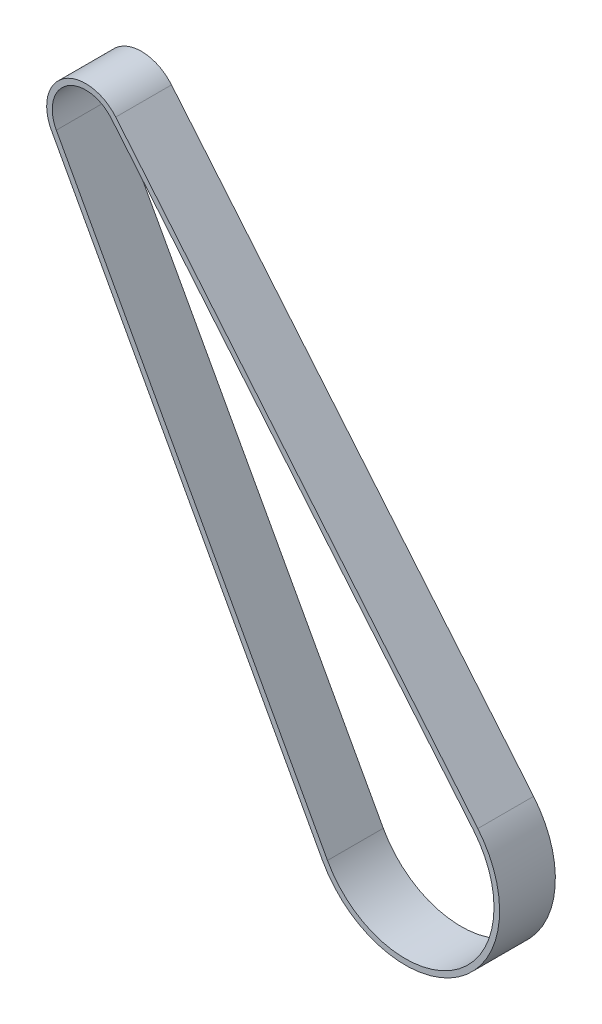
from build123d import *

# Parameters (mm, degrees)
EXTRU_MINCE1_DEPTH = 10


with BuildPart() as part:
    # Esquisse2 → Extru.-Mince1 (new body)
    with BuildSketch(Plane.XY):
        with BuildLine():
            Line((42.474865666, -92.445618956), (-6.144584761, -3.353219068))
            ThreePointArc((-6.144584761, -3.353219068), (-3.933900634, 5.790028135), (5.380773293, 4.477418762))
            Line((5.380773293, 4.477418762), (70.300372966, -73.540221908))
            ThreePointArc((70.300372966, -73.540221908), (66.807208975, -98.328772274), (42.474865666, -92.445618956))
        make_face()
        with BuildLine():
            Line((43.352663489, -91.966587661), (-5.266786938, -2.874187773))
            ThreePointArc((-5.266786938, -2.874187773), (-3.371914829, 4.962881258), (4.612091394, 3.83778751))
            Line((4.612091394, 3.83778751), (69.531691067, -74.17985316))
            ThreePointArc((69.531691067, -74.17985316), (66.245223171, -97.501625397), (43.352663489, -91.966587661))
        make_face(mode=Mode.SUBTRACT)
    extrude(amount=EXTRU_MINCE1_DEPTH)


solid = part.part
